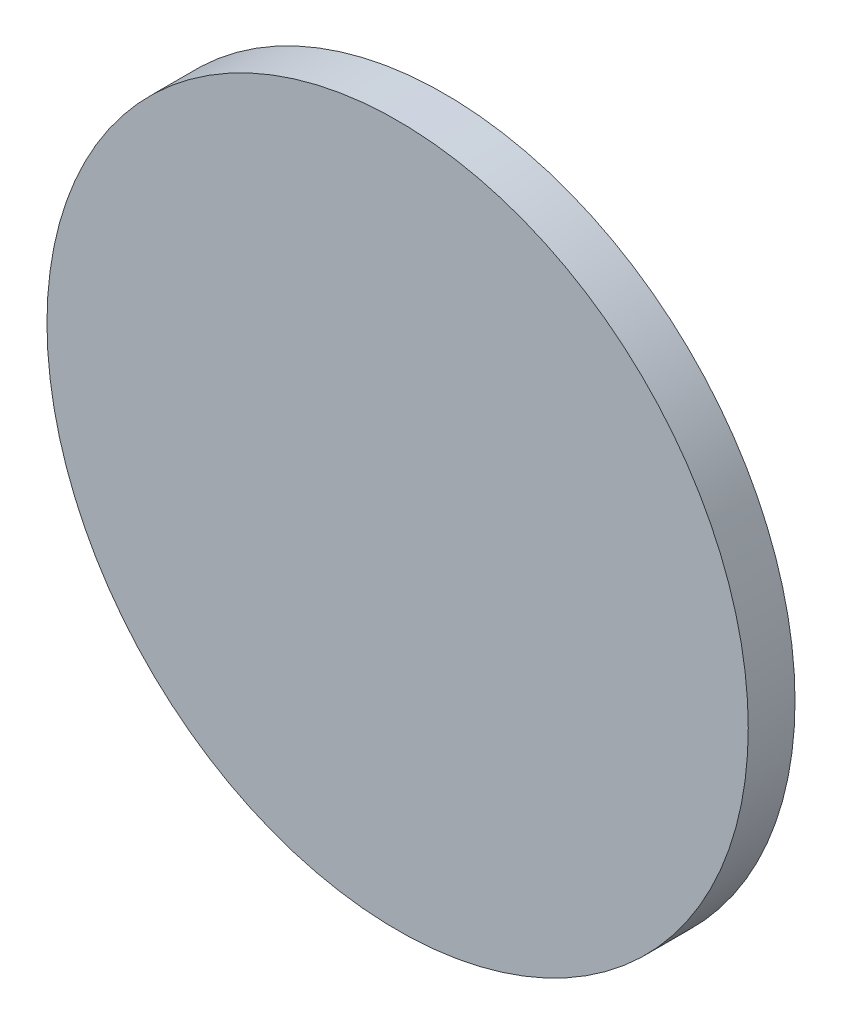
from build123d import *

# Parameters (mm, degrees)
SKETCH1_R           = 37.5
BOSS_EXTRUDE1_DEPTH = 5


with BuildPart() as part:
    # Sketch1 → Boss-Extrude1 (new body)
    with BuildSketch(Plane.XY):
        Circle(SKETCH1_R)
    extrude(amount=BOSS_EXTRUDE1_DEPTH)


solid = part.part
